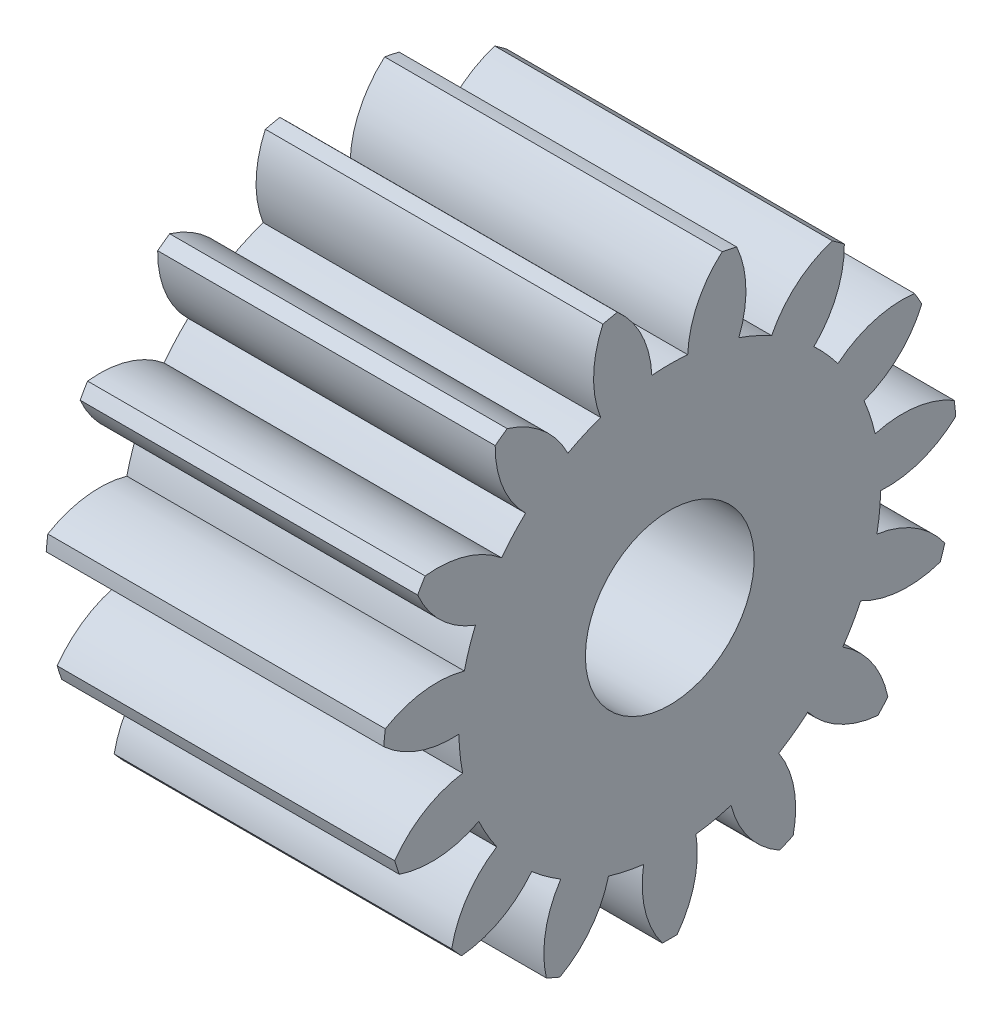
from build123d import *

# Parameters (mm, degrees)
BASPROSKE_W     = 10
BASPROSKE_H     = 8.5
TOOTHCUT_DEPTH  = 16.636495771
TEETHCUTS_COUNT = 15
TEETHCUTS_ANGLE = 336
BORSKE_R        = 2.5
BORE_DEPTH      = 50.0000508


with BuildPart() as part:
    # BasProSke → Base-Revolve (revolve)
    with BuildSketch(Plane(origin=(0, 0, 0), x_dir=(1, 0, 0), z_dir=(0, 1, 0)), mode=Mode.PRIVATE) as base_revolve_sk:
        with Locations((5, 4.25)):
            Rectangle(BASPROSKE_W, BASPROSKE_H)
    revolve(base_revolve_sk.sketch.rotate(Axis((-10, 0, 0), (1, 0, 0)), 180), axis=Axis((-10, 0, 0), (1, 0, 0)))

    # TooCutSke → ToothCut (cut, through all)
    with BuildSketch(Plane(origin=(0, 0, 0), x_dir=(0, 0, -1), z_dir=(1, 0, 0))):
        with BuildLine():
            ThreePointArc((0.531576138, 6.226349477), (0, 6.249), (-0.531576138, 6.226349477))
            ThreePointArc((-0.531576138, 6.226349477), (-0.830301624, 7.411024729), (-1.576608494, 8.378350125))
            ThreePointArc((-1.576608494, 8.378350125), (0, 8.5254), (1.576608494, 8.378350125))
            ThreePointArc((1.576608494, 8.378350125), (0.830301624, 7.411024729), (0.531576138, 6.226349477))
        make_face()
    toothcut = extrude(amount=TOOTHCUT_DEPTH, mode=Mode.SUBTRACT)

    # TeethCuts: ToothCut ×15 about axis
    teethcuts_axis = Axis((-10, 0, 0), (1, 0, 0))
    for i in range(1, TEETHCUTS_COUNT):
        add(toothcut.rotate(teethcuts_axis, i * TEETHCUTS_ANGLE / (TEETHCUTS_COUNT - 1)), mode=Mode.SUBTRACT)

    # BorSke → Bore (cut, symmetric)
    with BuildSketch(Plane(origin=(0, 0, 0), x_dir=(0, 0, -1), z_dir=(1, 0, 0))):
        with Locations(Location((0, 0, 0), (0, 0, 180))):
            Circle(BORSKE_R)
    extrude(amount=BORE_DEPTH, both=True, mode=Mode.SUBTRACT)


solid = part.part
